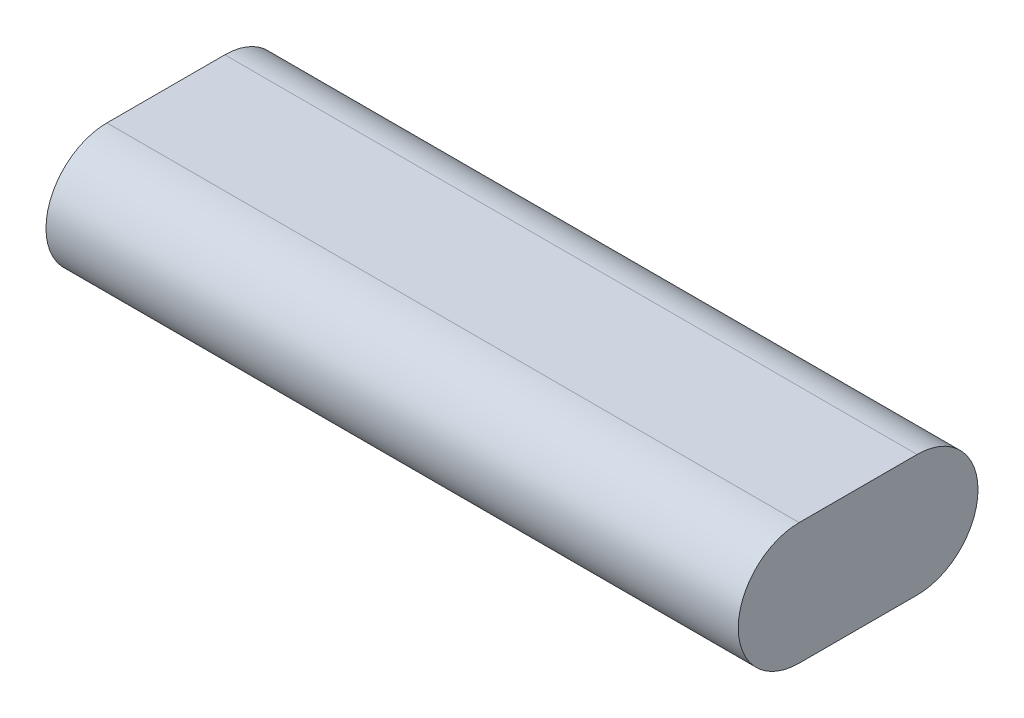
from build123d import *

# Parameters (mm, degrees)
BOSS_EXTRUDE1_DEPTH = 68.58


with BuildPart() as part:
    # Sketch1 → Boss-Extrude1 (new body, symmetric)
    with BuildSketch(Plane(origin=(0, 0, 0), x_dir=(0, 0, -1), z_dir=(1, 0, 0))):
        with BuildLine():
            Line((-11.684, 12.065), (11.684, 12.065))
            ThreePointArc((11.684, 12.065), (23.749, 0), (11.684, -12.065))
            Line((11.684, -12.065), (-11.684, -12.065))
            ThreePointArc((-11.684, -12.065), (-23.749, 0), (-11.684, 12.065))
        make_face()
    extrude(amount=BOSS_EXTRUDE1_DEPTH, both=True)


solid = part.part
